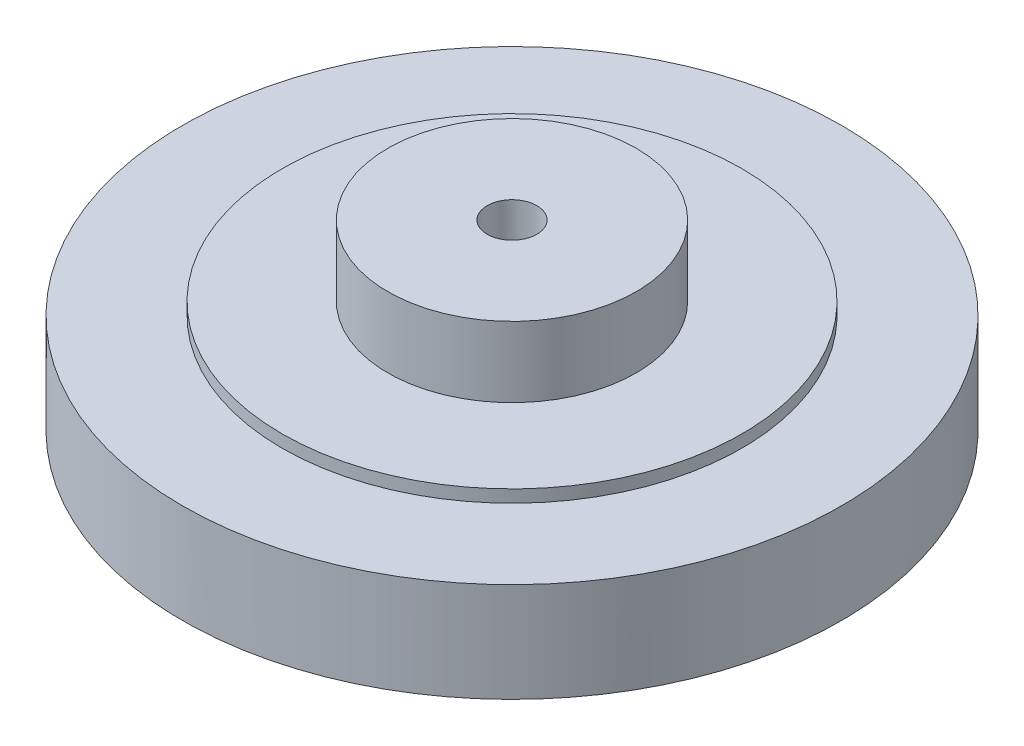
from build123d import *

# Parameters (mm, degrees)
SKETCH2_R           = 39.788735773
SKETCH2_R_2         = 27.75
BOSS_EXTRUDE1_DEPTH = 12
BOSS_EXTRUDE2_START = 1.5
SKETCH3_R           = 27.75
SKETCH3_R_2         = 3
BOSS_EXTRUDE2_DEPTH = 15


with BuildPart() as part:
    # Sketch1 → Revolve1 (revolve)
    with BuildSketch(Plane.XY):
        Polygon((3, 22), (3, 0), (27.75, 0), (27.75, 12), (15, 12), (15, 22), align=None)
    revolve(axis=Axis((0, 0, 0), (0, 1, 0)))



with BuildPart() as body_2:
    # Sketch2 → Boss-Extrude1 (new body)
    with BuildSketch(Plane.XZ):
        Circle(SKETCH2_R)
        Circle(SKETCH2_R_2, mode=Mode.SUBTRACT)
    extrude(amount=-BOSS_EXTRUDE1_DEPTH)


with BuildPart() as part_1:
    add(part.part)

    add(body_2.part)  # Boss-Extrude2 merges body 2
    # Sketch3 → Boss-Extrude2 (add)
    with BuildSketch(Plane.XZ.offset(BOSS_EXTRUDE2_START)):
        Circle(SKETCH3_R)
        Circle(SKETCH3_R_2, mode=Mode.SUBTRACT)
    extrude(amount=-BOSS_EXTRUDE2_DEPTH)


solid = part_1.part
